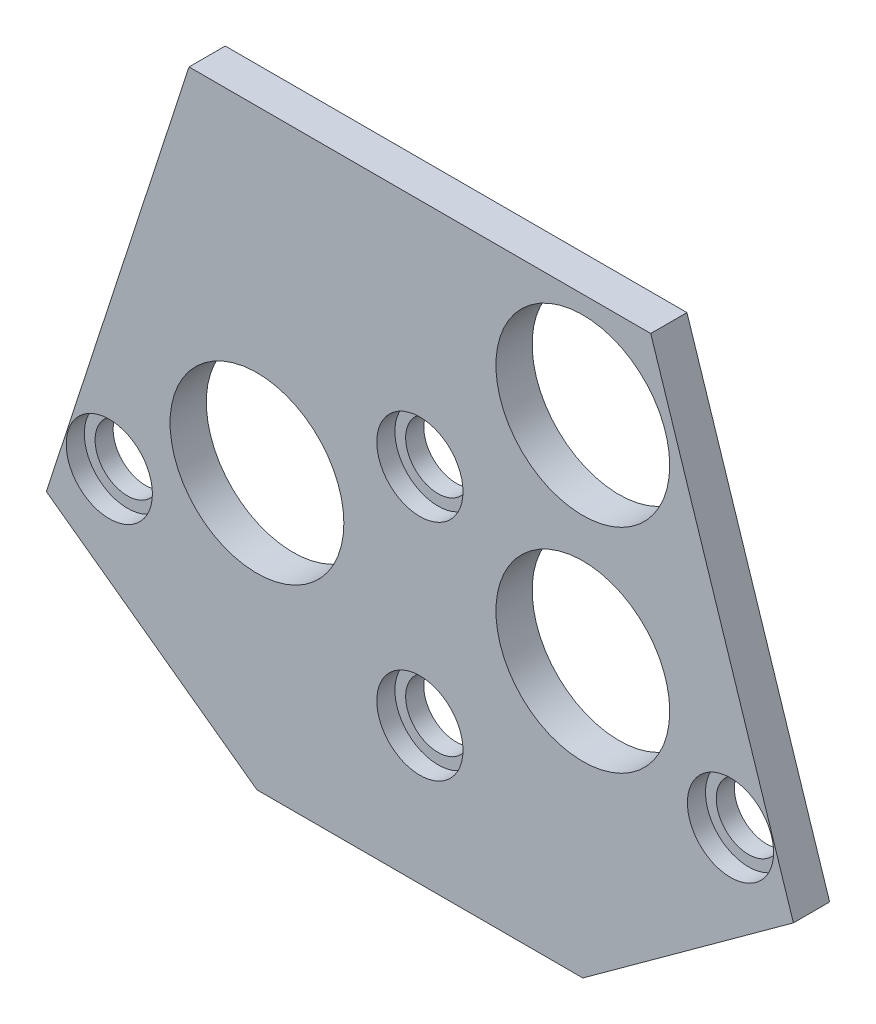
from build123d import *

# Parameters (mm, degrees)
SKETCH2_R           = 4.7625
SKETCH2_R_2         = 12.8
BOSS_EXTRUDE2_DEPTH = 5.334
CUT_EXTRUDE3_START  = -2.667
SKETCH3_R           = 6.35
SKETCH3_R_2         = 4.7625
CUT_EXTRUDE3_DEPTH  = 2.667
SKETCH3_2_R         = 4.7625
CUT_EXTRUDE4_DEPTH  = 87.872399887


with BuildPart() as part:
    # Sketch2 → Boss-Extrude2 (new body)
    with BuildSketch(Plane.XY):
        Polygon((-55.022779977, 2.330692017), (-24, -20.208676973), (24, -20.208676973), (55.022779977, 2.330692017), (34.005948181, 67.013849238), (-34.005948181, 67.013849238), align=None)
        Circle(SKETCH2_R, mode=Mode.SUBTRACT)
        with Locations((-24, 20.208676973)):
            Circle(SKETCH2_R_2, mode=Mode.SUBTRACT)
        with Locations((24, 20.208676973)):
            Circle(SKETCH2_R_2, mode=Mode.SUBTRACT)
        with Locations((24, 51.583676973)):
            Circle(SKETCH2_R_2, mode=Mode.SUBTRACT)
    extrude(amount=BOSS_EXTRUDE2_DEPTH)

    # Sketch3 → Cut-Extrude3 (cut)
    # profile 1 of 4: a face of its own
    with BuildSketch(Plane.XY.offset(5.334).offset(CUT_EXTRUDE3_START)):
        Circle(SKETCH3_R)
        Circle(SKETCH3_R_2, mode=Mode.SUBTRACT)
    # profile 2 of 4: a face of its own
    with BuildSketch(Plane.XY.offset(5.334).offset(CUT_EXTRUDE3_START)):
        with Locations((45.751679669, 9.848845061)):
            Circle(SKETCH3_R)
        with Locations((45.751679669, 9.848845061)):
            Circle(SKETCH3_R_2, mode=Mode.SUBTRACT)
    # profile 3 of 4: a face of its own
    with BuildSketch(Plane.XY.offset(5.334).offset(CUT_EXTRUDE3_START)):
        with Locations((0, 33.008676973)):
            Circle(SKETCH3_R)
        with Locations((0, 33.008676973)):
            Circle(SKETCH3_R_2, mode=Mode.SUBTRACT)
    # profile 4 of 4: a face of its own
    with BuildSketch(Plane.XY.offset(5.334).offset(CUT_EXTRUDE3_START)):
        with Locations((-45.751679669, 9.848845061)):
            Circle(SKETCH3_R)
        with Locations((-45.751679669, 9.848845061)):
            Circle(SKETCH3_R_2, mode=Mode.SUBTRACT)
    extrude(amount=CUT_EXTRUDE3_DEPTH, mode=Mode.SUBTRACT)

    # Sketch3_2 → Cut-Extrude4 (cut, through all)
    with BuildSketch(Plane.XY.offset(5.334)):
        with Locations((45.751679669, 9.848845061)):
            Circle(SKETCH3_2_R)
        with Locations((0, 33.008676973)):
            Circle(SKETCH3_2_R)
        with Locations((-45.751679669, 9.848845061)):
            Circle(SKETCH3_2_R)
    extrude(amount=-CUT_EXTRUDE4_DEPTH, mode=Mode.SUBTRACT)


solid = part.part
